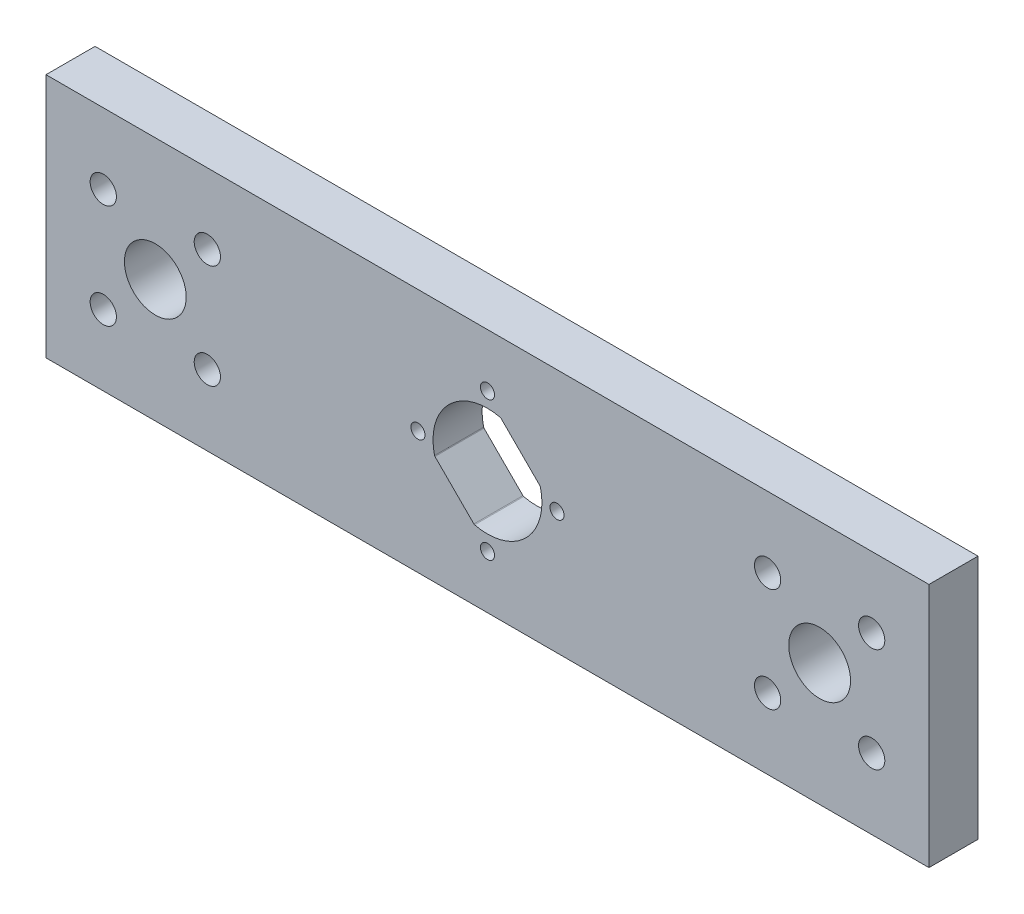
from build123d import *

# Parameters (mm, degrees)
SKETCH1_W           = 114.3
SKETCH1_H           = 31.75
SKETCH1_R           = 0.9115
SKETCH1_R_2         = 4
SKETCH1_R_3         = 1.7
BOSS_EXTRUDE1_DEPTH = 6.35


with BuildPart() as part:
    # Sketch1 → Boss-Extrude1 (new body)
    with BuildSketch(Plane.XY):
        Rectangle(SKETCH1_W, SKETCH1_H)
        with Locations((-9.000000134, 0)):
            Circle(SKETCH1_R, mode=Mode.SUBTRACT)
        with Locations((0, -9.000000134)):
            Circle(SKETCH1_R, mode=Mode.SUBTRACT)
        with Locations((9.000000134, 0)):
            Circle(SKETCH1_R, mode=Mode.SUBTRACT)
        with Locations((0, 9.000000134)):
            Circle(SKETCH1_R, mode=Mode.SUBTRACT)
        with Locations((-43.000000106, 0)):
            Circle(SKETCH1_R_2, mode=Mode.SUBTRACT)
        with Locations((43.000000106, 0)):
            Circle(SKETCH1_R_2, mode=Mode.SUBTRACT)
        with Locations((-36.264808015, 6.735192091)):
            Circle(SKETCH1_R_3, mode=Mode.SUBTRACT)
        with Locations((-49.735192197, 6.735192091)):
            Circle(SKETCH1_R_3, mode=Mode.SUBTRACT)
        with Locations((-36.264808015, -6.735192091)):
            Circle(SKETCH1_R_3, mode=Mode.SUBTRACT)
        with Locations((-49.735192197, -6.735192091)):
            Circle(SKETCH1_R_3, mode=Mode.SUBTRACT)
        with Locations((49.735192197, -6.735192091)):
            Circle(SKETCH1_R_3, mode=Mode.SUBTRACT)
        with Locations((36.264808015, -6.735192091)):
            Circle(SKETCH1_R_3, mode=Mode.SUBTRACT)
        with Locations((36.264808015, 6.735192091)):
            Circle(SKETCH1_R_3, mode=Mode.SUBTRACT)
        with Locations((49.735192197, 6.735192091)):
            Circle(SKETCH1_R_3, mode=Mode.SUBTRACT)
        with BuildLine():
            Line((-6.79791666, -1.758075393), (-1.758075393, -6.79791666))
            ThreePointArc((-1.758075393, -6.79791666), (-1.714608205, -6.830865544), (-1.663855614, -6.850845531))
            ThreePointArc((-1.663855614, -6.850845531), (4.985102807, -4.985102807), (6.850845531, 1.663855614))
            ThreePointArc((6.850845531, 1.663855614), (6.830865544, 1.714608205), (6.79791666, 1.758075393))
            Line((6.79791666, 1.758075393), (1.758075393, 6.79791666))
            ThreePointArc((1.758075393, 6.79791666), (1.714608205, 6.830865544), (1.663855614, 6.850845531))
            ThreePointArc((1.663855614, 6.850845531), (-4.985102807, 4.985102807), (-6.850845531, -1.663855614))
            ThreePointArc((-6.850845531, -1.663855614), (-6.830865544, -1.714608205), (-6.79791666, -1.758075393))
        make_face(mode=Mode.SUBTRACT)
    extrude(amount=BOSS_EXTRUDE1_DEPTH)


solid = part.part
